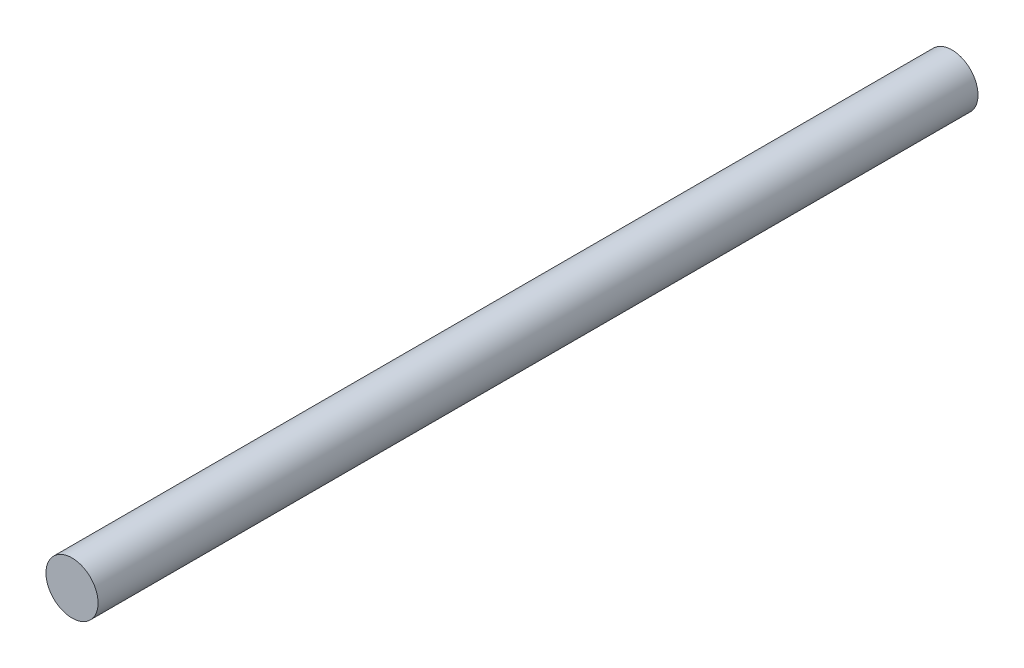
from build123d import *

# Parameters (mm, degrees)
SKETCH1_R           = 12.5
BOSS_EXTRUDE1_DEPTH = 422


with BuildPart() as part:
    # Sketch1 → Boss-Extrude1 (new body)
    with BuildSketch(Plane.XY):
        Circle(SKETCH1_R)
    extrude(amount=BOSS_EXTRUDE1_DEPTH)


solid = part.part
